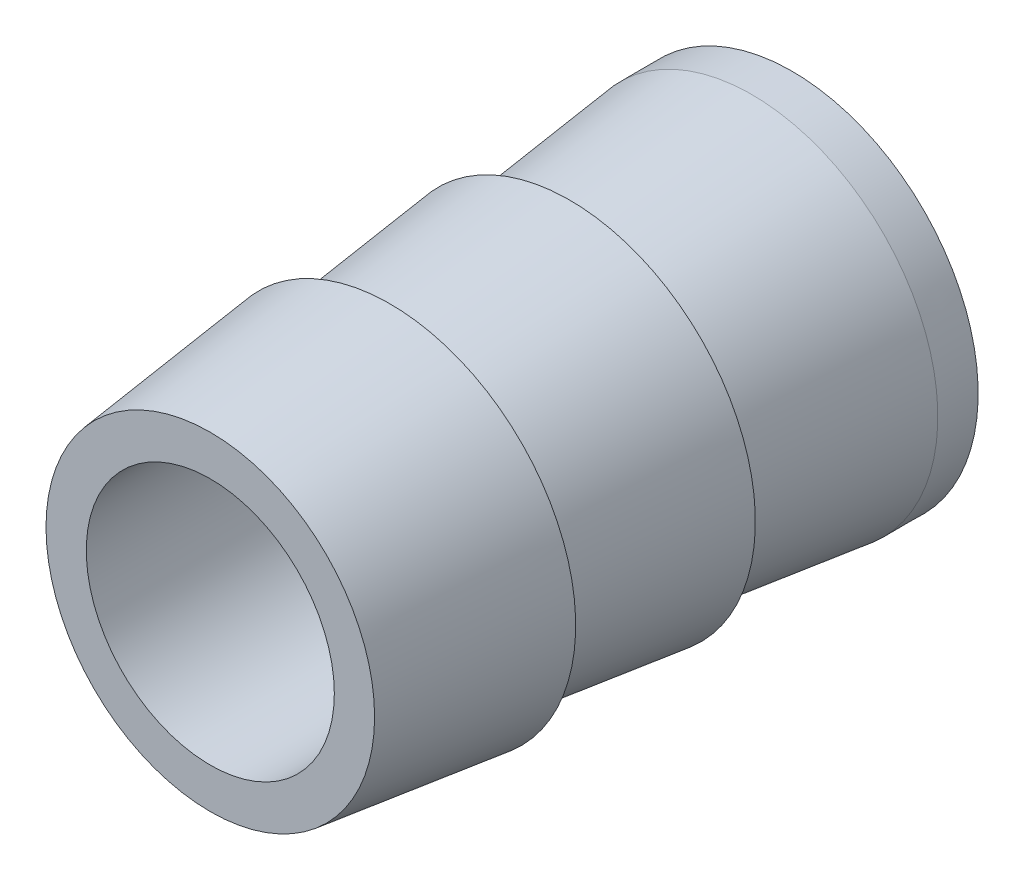
from build123d import *

# Parameters (mm, degrees)
SKETCH3_R          = 3.175
CUT_EXTRUDE1_DEPTH = 15.893870686


with BuildPart() as part:
    # Sketch2 → Barbfitting(Mcmaster) (revolve)
    with BuildSketch(Plane(origin=(0, 0, 0), x_dir=(0, 0, -1), z_dir=(1, 0, 0))):
        Polygon((8.7391875, 0), (-6.154683186, 0), (-6.154683186, 4.205934994), (-6.005566814, 4.223690006), (-1.554901936, 4.753622494), (-1.554901936, 4.205934994), (-1.405785564, 4.223690006), (3.044879314, 4.753622494), (3.044879314, 4.205934994), (3.193995686, 4.223690006), (7.707996691, 4.76116381), (8.7391875, 4.7625), align=None)
    revolve(axis=Axis((0, 0, -8.7391875), (0, 0, 1)))

    # Sketch3 → Cut-Extrude1 (cut, through all)
    with BuildSketch(Plane.XY.offset(6.154683186)):
        Circle(SKETCH3_R)
    extrude(amount=-CUT_EXTRUDE1_DEPTH, mode=Mode.SUBTRACT)


solid = part.part
